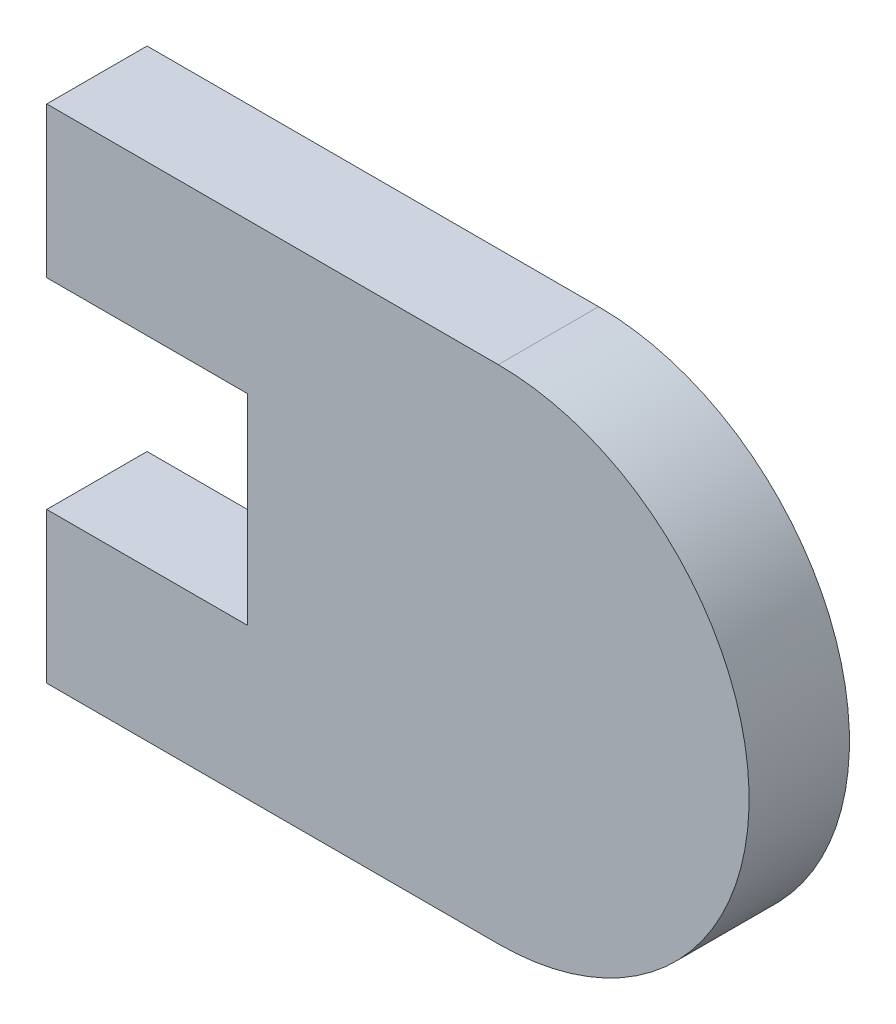
from build123d import *

# Parameters (mm, degrees)
BOSS_EXTRUDE1_DEPTH = 3.175


with BuildPart() as part:
    # Sketch1 → Boss-Extrude1 (new body)
    with BuildSketch(Plane.XY):
        with BuildLine():
            Line((0, 0), (14.2875, 0))
            ThreePointArc((14.2875, 0), (22.225, 7.9375), (14.2875, 15.875))
            Line((14.2875, 15.875), (0, 15.875))
            Line((0, 15.875), (0, 11.1125))
            Line((0, 11.1125), (6.35, 11.1125))
            Line((6.35, 11.1125), (6.35, 4.7625))
            Line((6.35, 4.7625), (0, 4.7625))
            Line((0, 4.7625), (0, 0))
        make_face()
    extrude(amount=BOSS_EXTRUDE1_DEPTH)


solid = part.part
